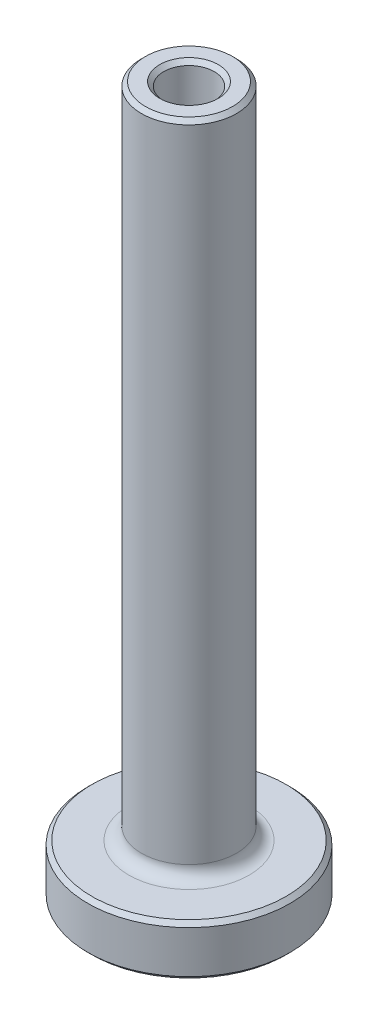
from build123d import *

# Parameters (mm, degrees)
FILLET1_R     = 0.396875
FILLET2_R     = 0.79375
CHAMFER1_SIZE = 0.254
CHAMFER2_SIZE = 0.127


with BuildPart() as part:
    # Sketch1 → Revolve1 (revolve)
    with BuildSketch(Plane.XY):
        Polygon((2.286, 0), (2.286, 12.7), (1.5875, 12.7), (1.5875, 44.45), (2.9845, 44.45), (2.9845, 3.175), (6.35, 3.175), (6.35, 0), align=None)
    revolve(axis=Axis((0, 5.299175628, 0), (0, -1, 0)))

    # Fillet1
    fillet1_edges = [part.edges().sort_by_distance(p)[0] for p in [
        (-2.286, 12.7, 0),
    ]]
    fillet(fillet1_edges, radius=FILLET1_R)

    # Fillet2
    fillet2_edges = [part.edges().sort_by_distance(p)[0] for p in [
        (-2.9845, 3.175, 0),
    ]]
    fillet(fillet2_edges, radius=FILLET2_R)

    # Chamfer1
    chamfer1_edges = [part.edges().sort_by_distance(p)[0] for p in [
        (-6.35, 0, 0),
        (-6.35, 3.175, 0),
        (-2.9845, 44.45, 0),
        (-1.5875, 44.45, 0),
        (-2.286, 0, 0),
    ]]
    chamfer(chamfer1_edges, length=CHAMFER1_SIZE)

    # Chamfer2
    chamfer2_edges = [part.edges().sort_by_distance(p)[0] for p in [
        (-1.5875, 12.7, 0),
    ]]
    chamfer(chamfer2_edges, length=CHAMFER2_SIZE)


solid = part.part
